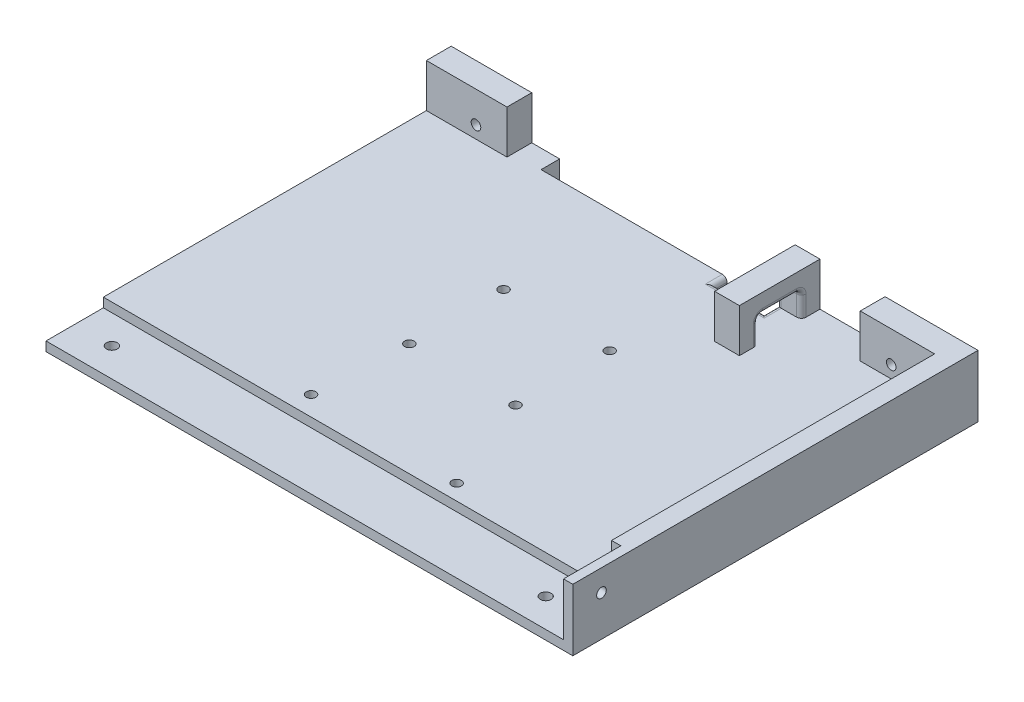
from build123d import *

# Parameters (mm, degrees)
BOSS_EXTRUDE1_DEPTH = 6
SKETCH2_W           = 26
SKETCH2_H           = 8
SKETCH2_W_2         = 30
BOSS_EXTRUDE2_DEPTH = 14
SKETCH3_R           = 1.55
CUT_EXTRUDE1_DEPTH  = 9
SKETCH4_W           = 170
SKETCH4_H           = 18.5
CUT_EXTRUDE2_DEPTH  = 3
SKETCH5_R           = 1.75
CUT_EXTRUDE3_DEPTH  = 3
BOSS_EXTRUDE3_REACH = 22
SKETCH8_R           = 1.55
CUT_EXTRUDE4_DEPTH  = 4
CUT_EXTRUDE5_REACH  = 8
SKETCH9_W           = 16
SKETCH9_H           = 10
SKETCH10_W          = 8
SKETCH10_H          = 26
BOSS_EXTRUDE4_DEPTH = 14
CUT_EXTRUDE6_REACH  = 121
FILLET1_R           = 1.5
SKETCH12_R          = 1.55
CUT_EXTRUDE7_DEPTH  = 14
CUT_EXTRUDE8_REACH  = 8
SKETCH13_R          = 1.55


with BuildPart() as part:
    # Sketch1 → Boss-Extrude1 (new body)
    with BuildSketch(Plane(origin=(0, 0, 0), x_dir=(1, 0, 0), z_dir=(0, 1, 0))):
        Polygon((-85, 65.375), (-85, -65.375), (85, -65.375), (85, 65.375), (10, 65.375), (10, 59.375), (-50, 59.375), (-50, 65.375), align=None)
    extrude(amount=BOSS_EXTRUDE1_DEPTH)

    # Sketch2 → Boss-Extrude2 (add)
    with BuildSketch(Plane(origin=(0, 6, 0), x_dir=(1, 0, 0), z_dir=(0, 1, 0))):
        with Locations((-72, 61.375)):
            Rectangle(SKETCH2_W, SKETCH2_H)
        with Locations((70, 61.375)):
            Rectangle(SKETCH2_W_2, SKETCH2_H)
    extrude(amount=BOSS_EXTRUDE2_DEPTH)

    # Sketch3 → Cut-Extrude1 (cut, through all)
    with BuildSketch(Plane.XY.offset(-57.375)):
        with Locations((-69, 10)):
            Circle(SKETCH3_R)
        with Locations((65, 10)):
            Circle(SKETCH3_R)
    extrude(amount=-CUT_EXTRUDE1_DEPTH, mode=Mode.SUBTRACT)

    # Sketch4 → Cut-Extrude2 (cut)
    with BuildSketch(Plane(origin=(0, 6, 0), x_dir=(1, 0, 0), z_dir=(0, 1, 0))):
        with Locations((0, -56.125)):
            Rectangle(SKETCH4_W, SKETCH4_H)
    extrude(amount=-CUT_EXTRUDE2_DEPTH, mode=Mode.SUBTRACT)

    # Sketch5 → Cut-Extrude3 (cut)
    with BuildSketch(Plane(origin=(0, 3, 0), x_dir=(1, 0, 0), z_dir=(0, 1, 0))):
        with Locations((-73, -56.125)):
            Circle(SKETCH5_R)
        with Locations((67, -56.125)):
            Circle(SKETCH5_R)
    extrude(amount=-CUT_EXTRUDE3_DEPTH, mode=Mode.SUBTRACT)

    # Sketch7 → Boss-Extrude3 (add, up to next)
    with BuildSketch(Plane(origin=(0, 20, 0), x_dir=(1, 0, 0), z_dir=(0, 1, 0)), mode=Mode.PRIVATE) as boss_extrude3_sk1:
        Polygon((85, -65.375), (85, 57.375), (79, 57.375), (79, -46.875), (82, -46.875), (82, -65.375), align=None)
    boss_extrude3_tool1 = extrude(boss_extrude3_sk1.sketch, amount=-BOSS_EXTRUDE3_REACH, mode=Mode.PRIVATE) - part.part
    add(boss_extrude3_tool1.solids().sort_by_distance((82.122247, 20, -0.248073))[0])

    # Sketch8 → Cut-Extrude4 (cut, through all)
    with BuildSketch(Plane.ZY.offset(-82)):
        with Locations((56.125, 13)):
            Circle(SKETCH8_R)
    extrude(amount=-CUT_EXTRUDE4_DEPTH, mode=Mode.SUBTRACT)

    # Sketch9 → Cut-Extrude5 (cut, up to next)
    with BuildSketch(Plane(origin=(0, 6, 0), x_dir=(1, 0, 0), z_dir=(0, 1, 0)), mode=Mode.PRIVATE) as cut_extrude5_sk1:
        with Locations((18, 60.375)):
            Rectangle(SKETCH9_W, SKETCH9_H)
    cut_extrude5_tool1 = extrude(cut_extrude5_sk1.sketch, amount=-CUT_EXTRUDE5_REACH, mode=Mode.PRIVATE) & part.part
    add(cut_extrude5_tool1.solids().sort_by_distance((18, 6, -60.375))[0], mode=Mode.SUBTRACT)

    # Sketch10 → Boss-Extrude4 (add)
    with BuildSketch(Plane(origin=(0, 6, 0), x_dir=(1, 0, 0), z_dir=(0, 1, 0))):
        with Locations((30, 52.375)):
            Rectangle(SKETCH10_W, SKETCH10_H)
    extrude(amount=BOSS_EXTRUDE4_DEPTH)

    # Sketch11 → Cut-Extrude6 (cut, up to next)
    with BuildSketch(Plane(origin=(34, 0, 0), x_dir=(0, 0, -1), z_dir=(1, 0, 0)), mode=Mode.PRIVATE) as cut_extrude6_sk1:
        Polygon((45.375, 12), (45.375, 6), (59.375, 6), (59.375, 12), (59.375, 14), (45.375, 14), align=None)
    cut_extrude6_tool1 = extrude(cut_extrude6_sk1.sketch, amount=-CUT_EXTRUDE6_REACH, mode=Mode.PRIVATE) & part.part
    add(cut_extrude6_tool1.solids().sort_by_distance((34, 10, -52.375))[0], mode=Mode.SUBTRACT)

    # Fillet1
    fillet1_edges = [part.edges().sort_by_distance(p)[0] for p in [
        (26, 6, -57.375),
        (18, 6, -55.375),
        (10, 6, -57.375),
        (26, 10, -45.375),
        (26, 14, -52.375),
        (26, 10, -59.375),
        (34, 10, -59.375),
        (34, 14, -52.375),
        (34, 10, -45.375),
        (30, 14, -45.375),
        (30, 14, -59.375),
    ]]
    fillet(fillet1_edges, radius=FILLET1_R)

    # Sketch12 → Cut-Extrude7 (cut)
    with BuildSketch(Plane(origin=(0, 6, 0), x_dir=(1, 0, 0), z_dir=(0, 1, 0))):
        with Locations((24, -41.875)):
            Circle(SKETCH12_R)
        with Locations((-24.26, -40.575)):
            Circle(SKETCH12_R)
    extrude(amount=-CUT_EXTRUDE7_DEPTH, mode=Mode.SUBTRACT)

    # Sketch13 → Cut-Extrude8 (cut, up to next)
    with BuildSketch(Plane(origin=(0, 6, 0), x_dir=(1, 0, 0), z_dir=(0, 1, 0)), mode=Mode.PRIVATE) as cut_extrude8_sk1:
        with Locations((11.685222517, 19.828524859)):
            Circle(SKETCH13_R)
    cut_extrude8_tool1 = extrude(cut_extrude8_sk1.sketch, amount=-CUT_EXTRUDE8_REACH, mode=Mode.PRIVATE) & part.part
    add(cut_extrude8_tool1.solids().sort_by_distance((11.685223, 6, -19.828525))[0], mode=Mode.SUBTRACT)
    # Sketch13 → Cut-Extrude8 (cut, up to next)
    with BuildSketch(Plane(origin=(0, 6, 0), x_dir=(1, 0, 0), z_dir=(0, 1, 0)), mode=Mode.PRIVATE) as cut_extrude8_sk2:
        with Locations((-22.560396417, 19.828524859)):
            Circle(SKETCH13_R)
    cut_extrude8_tool2 = extrude(cut_extrude8_sk2.sketch, amount=-CUT_EXTRUDE8_REACH, mode=Mode.PRIVATE) & part.part
    add(cut_extrude8_tool2.solids().sort_by_distance((-22.560396, 6, -19.828525))[0], mode=Mode.SUBTRACT)
    # Sketch13 → Cut-Extrude8 (cut, up to next)
    with BuildSketch(Plane(origin=(0, 6, 0), x_dir=(1, 0, 0), z_dir=(0, 1, 0)), mode=Mode.PRIVATE) as cut_extrude8_sk3:
        with Locations((11.685222517, -10.544533108)):
            Circle(SKETCH13_R)
    cut_extrude8_tool3 = extrude(cut_extrude8_sk3.sketch, amount=-CUT_EXTRUDE8_REACH, mode=Mode.PRIVATE) & part.part
    add(cut_extrude8_tool3.solids().sort_by_distance((11.685223, 6, 10.544533))[0], mode=Mode.SUBTRACT)
    # Sketch13 → Cut-Extrude8 (cut, up to next)
    with BuildSketch(Plane(origin=(0, 6, 0), x_dir=(1, 0, 0), z_dir=(0, 1, 0)), mode=Mode.PRIVATE) as cut_extrude8_sk4:
        with Locations((-22.560396417, -10.544533108)):
            Circle(SKETCH13_R)
    cut_extrude8_tool4 = extrude(cut_extrude8_sk4.sketch, amount=-CUT_EXTRUDE8_REACH, mode=Mode.PRIVATE) & part.part
    add(cut_extrude8_tool4.solids().sort_by_distance((-22.560396, 6, 10.544533))[0], mode=Mode.SUBTRACT)


solid = part.part
